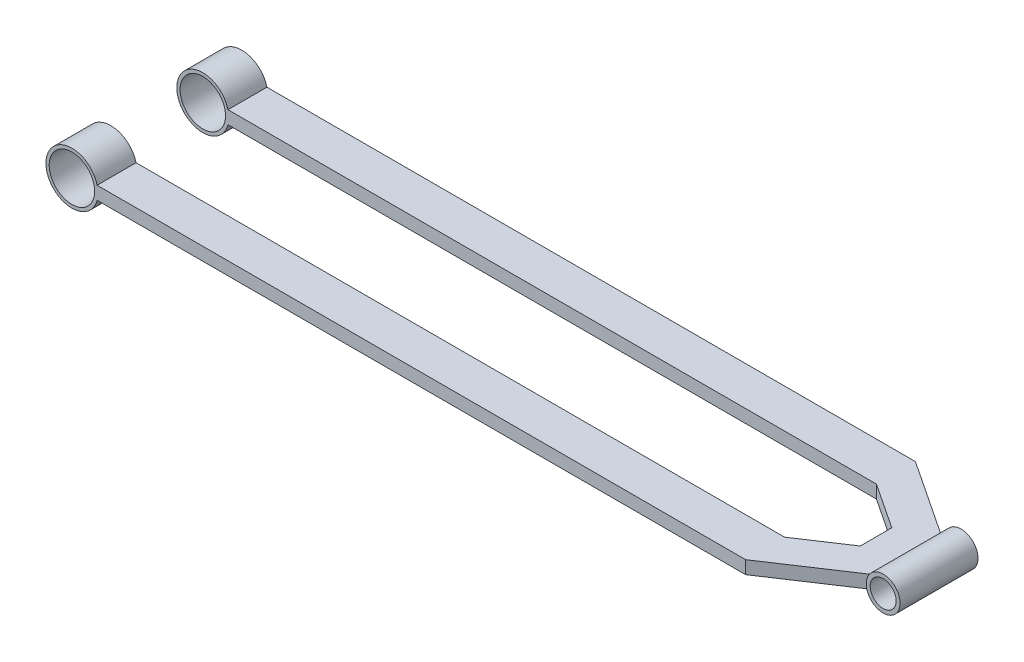
from build123d import *

# Parameters (mm, degrees)
SKETCH2_R           = 20
SKETCH2_R_2         = 17.5
BOSS_EXTRUDE1_DEPTH = 30
SKETCH3_R           = 20
SKETCH3_R_2         = 17.5
BOSS_EXTRUDE2_DEPTH = 30
BOSS_EXTRUDE3_DEPTH = 5
SKETCH5_R           = 13
SKETCH5_R_2         = 10
BOSS_EXTRUDE4_DEPTH = 30


with BuildPart() as part:
    # Sketch2 → Boss-Extrude1 (new body)
    with BuildSketch(Plane.XY.offset(-35.355)):
        Circle(SKETCH2_R)
        Circle(SKETCH2_R_2, mode=Mode.SUBTRACT)
    extrude(amount=-BOSS_EXTRUDE1_DEPTH)



with BuildPart() as body_2:
    # Sketch3 → Boss-Extrude2 (new body)
    with BuildSketch(Plane.XY.offset(35.355)):
        Circle(SKETCH3_R)
        Circle(SKETCH3_R_2, mode=Mode.SUBTRACT)
    extrude(amount=BOSS_EXTRUDE2_DEPTH)


with BuildPart() as part_1:
    add(part.part)

    add(body_2.part)  # Boss-Extrude3 merges body 2
    # Sketch4 → Boss-Extrude3 (add, symmetric)
    with BuildSketch(Plane(origin=(0, 0, 0), x_dir=(1, 0, 0), z_dir=(0, 1, 0))):
        Polygon((18.5, -65.355), (18.5, -35.355), (518.5, -35.355), (553.5, -12.138626468), (553.5, 12.138626468), (518.5, 35.355), (18.5, 35.355), (18.5, 65.355), (518.5, 65.355), (578.5, 25.555502516), (578.5, -25.555502516), (518.5, -65.355), align=None)
    extrude(amount=BOSS_EXTRUDE3_DEPTH, both=True)

    # Sketch5 → Boss-Extrude4 (add, symmetric)
    with BuildSketch(Plane.XY):
        with Locations((589, 0)):
            Circle(SKETCH5_R)
        with Locations((589, 0)):
            Circle(SKETCH5_R_2, mode=Mode.SUBTRACT)
    extrude(amount=BOSS_EXTRUDE4_DEPTH, both=True)


solid = part_1.part
